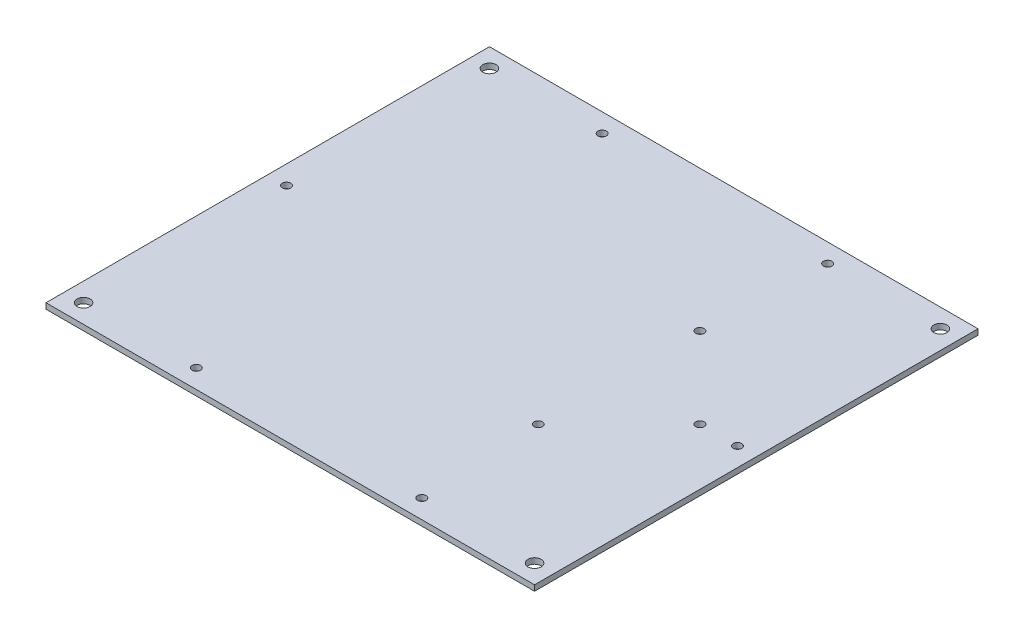
from build123d import *

# Parameters (mm, degrees)
SKETCH_1_W          = 260
SKETCH_1_H          = 236
EXTRUDE_1_DEPTH     = 3
SKETCH_2_R          = 2.25
SKETCH_2_R_2        = 3.5
CUT_EXTRUDE_1_DEPTH = 4
SKETCH1_R           = 2.25
CUT_EXTRUDE1_DEPTH  = 4


with BuildPart() as part:
    # Эскиз1 → Бобышка-Вытянуть1 (new body)
    with BuildSketch(Plane.XZ):
        with Locations((-88.97919902, 98.072268451)):
            Rectangle(SKETCH_1_W, SKETCH_1_H)
    extrude(amount=EXTRUDE_1_DEPTH)

    # Эскиз2 → Вырез-Вытянуть1 (cut, through all)
    with BuildSketch(Plane.XZ.offset(3)):
        with Locations((-208.97919902, 98.072268451)):
            Circle(SKETCH_2_R)
        with Locations((-148.97919902, -9.927731549)):
            Circle(SKETCH_2_R)
        with Locations((-28.97919902, -9.927731549)):
            Circle(SKETCH_2_R)
        with Locations((31.02080098, 98.072268451)):
            Circle(SKETCH_2_R)
        with Locations((-28.97919902, 206.072268451)):
            Circle(SKETCH_2_R)
        with Locations((-148.97919902, 206.072268451)):
            Circle(SKETCH_2_R)
        with Locations((-208.97919902, -9.927731549)):
            Circle(SKETCH_2_R_2)
        with Locations((-208.97919902, 206.072268451)):
            Circle(SKETCH_2_R_2)
        with Locations((31.02080098, -9.927731549)):
            Circle(SKETCH_2_R_2)
        with Locations((31.02080098, 206.072268451)):
            Circle(SKETCH_2_R_2)
    extrude(amount=-CUT_EXTRUDE_1_DEPTH, mode=Mode.SUBTRACT)

    # Sketch1 → Cut-Extrude1 (cut, through all)
    with BuildSketch(Plane(origin=(0, 0, 0), x_dir=(1, 0, 0), z_dir=(0, 1, 0))):
        with Locations((-31.97919902, -141.072268451)):
            Circle(SKETCH1_R)
        with Locations((11.02080098, -98.072268451)):
            Circle(SKETCH1_R)
        with Locations((-31.97919902, -55.072268451)):
            Circle(SKETCH1_R)
    extrude(amount=-CUT_EXTRUDE1_DEPTH, mode=Mode.SUBTRACT)


solid = part.part
